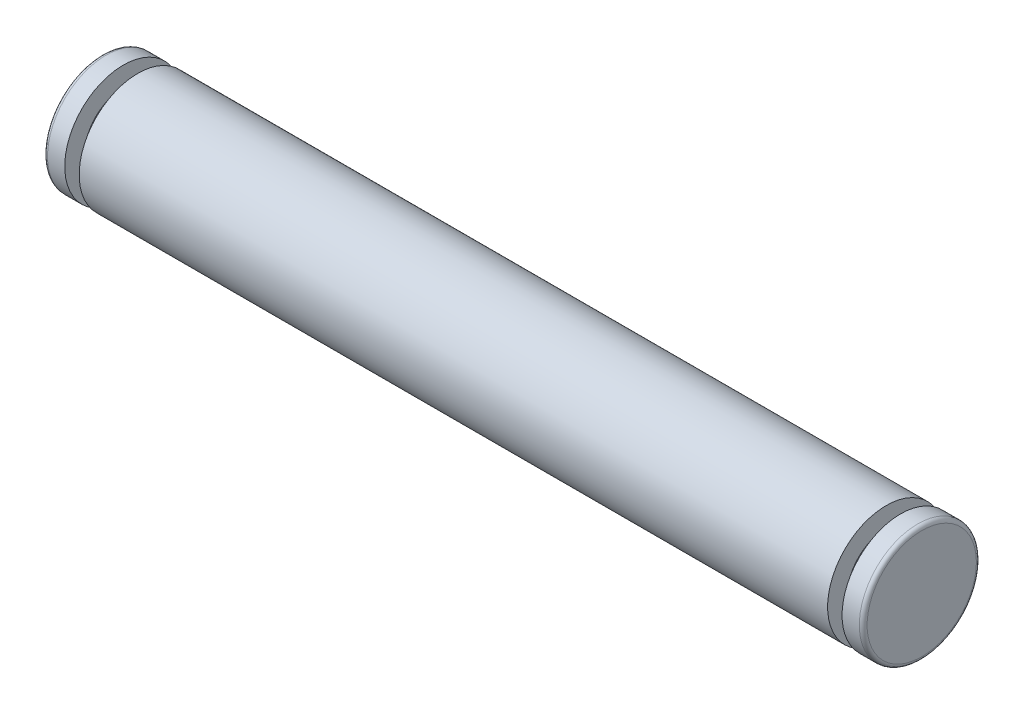
from build123d import *


with BuildPart() as part:
    # Sketch1 → Revolve1 (revolve)
    with BuildSketch(Plane(origin=(0, 0, 0), x_dir=(1, 0, 0), z_dir=(0, 1, 0))):
        with BuildLine():
            Line((-19.177, 3), (19.177, 3))
            Line((19.177, 3), (19.177, 2))
            Line((19.177, 2), (19.917, 2))
            Line((19.917, 2), (19.917, 3))
            Line((19.917, 3), (20.8, 3))
            ThreePointArc((20.8, 3), (20.941421356, 2.941421356), (21, 2.8))
            Line((21, 2.8), (21, 0))
            Line((21, 0), (-21, 0))
            Line((-21, 0), (-21, 2.8))
            ThreePointArc((-21, 2.8), (-20.941421356, 2.941421356), (-20.8, 3))
            Line((-20.8, 3), (-19.917, 3))
            Line((-19.917, 3), (-19.917, 2))
            Line((-19.917, 2), (-19.177, 2))
            Line((-19.177, 2), (-19.177, 3))
        make_face()
    revolve(axis=Axis((21, 0, 0), (-1, 0, 0)))


solid = part.part
